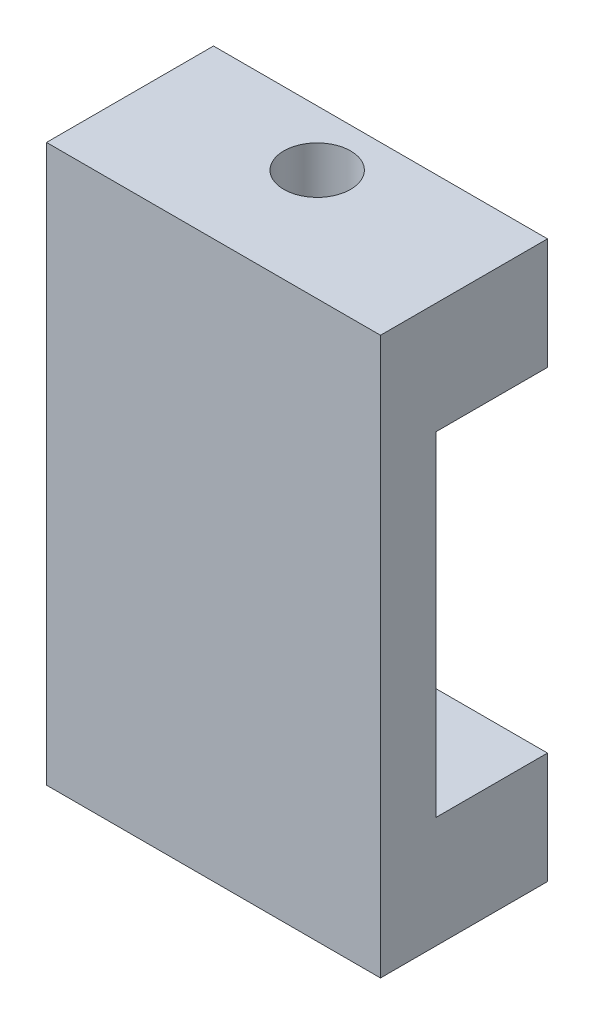
from build123d import *

# Parameters (mm, degrees)
BOSS_EXTRUDE2_DEPTH      = 2.5
BOSS_EXTRUDE2_DEPTH_BACK = 2.5
SKETCH4_W                = 30
SKETCH4_H                = 30
SKETCH5_W                = 30
SKETCH5_H                = 15
SKETCH5_R                = 3
BOSS_EXTRUDE3_DEPTH      = 10


with BuildPart() as part:
    # Sketch4 → Boss-Extrude2 (new, two sides: drawn at the far end of the back side and taken through both)
    with BuildSketch(Plane.XY.offset(-BOSS_EXTRUDE2_DEPTH_BACK)):
        Rectangle(SKETCH4_W, SKETCH4_H)
    extrude(amount=BOSS_EXTRUDE2_DEPTH + BOSS_EXTRUDE2_DEPTH_BACK)

    # Sketch5 → Boss-Extrude3 (add)
    with BuildSketch(Plane(origin=(0, 15, 0), x_dir=(1, 0, 0), z_dir=(0, 1, 0))):
        with Locations((0, 5)):
            Rectangle(SKETCH5_W, SKETCH5_H)
        with Locations((-0.685637394, 7.5)):
            Circle(SKETCH5_R, mode=Mode.SUBTRACT)
    boss_extrude3 = extrude(amount=BOSS_EXTRUDE3_DEPTH)

    # Mirror1: Boss-Extrude3 across plane
    add(boss_extrude3.mirror(Plane.ZX))


solid = part.part
